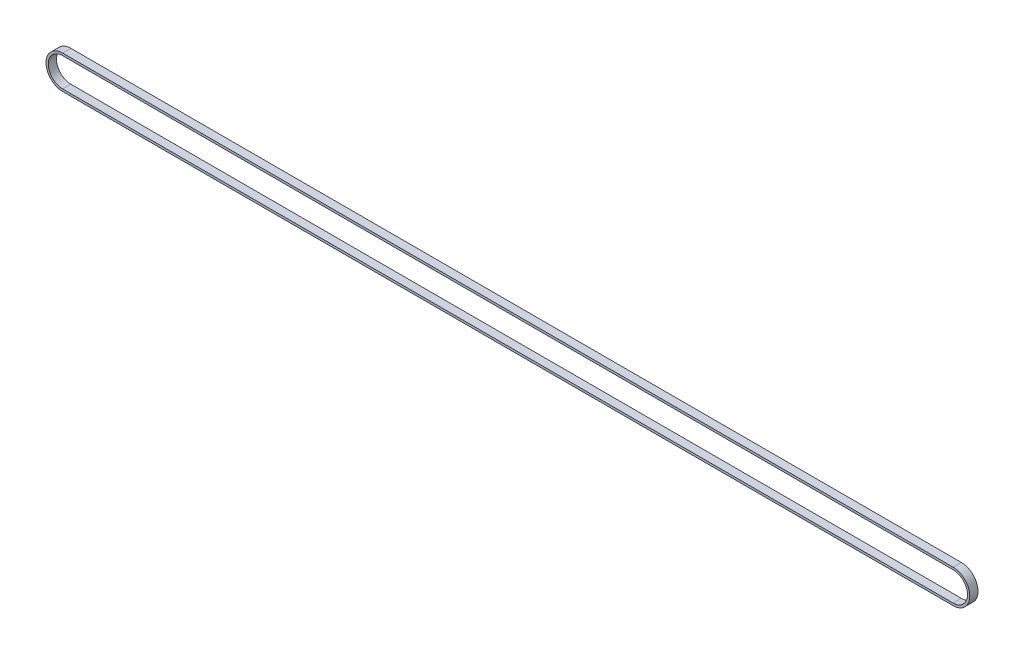
from build123d import *

# Parameters (mm, degrees)
EXTRUDE_THIN1_DEPTH = 2.5


with BuildPart() as part:
    # Sketch1 → Extrude-Thin1 (new body, symmetric)
    with BuildSketch(Plane.XY):
        with BuildLine():
            Line((541, -10.13), (0, -10.13))
            ThreePointArc((0, -10.13), (-10.13, 0), (0, 10.13))
            Line((0, 10.13), (541, 10.13))
            ThreePointArc((541, 10.13), (551.13, 0), (541, -10.13))
        make_face()
        with BuildLine():
            Line((541, -8.75), (0, -8.75))
            ThreePointArc((0, -8.75), (-8.75, 0), (0, 8.75))
            Line((0, 8.75), (541, 8.75))
            ThreePointArc((541, 8.75), (549.75, 0), (541, -8.75))
        make_face(mode=Mode.SUBTRACT)
    extrude(amount=EXTRUDE_THIN1_DEPTH, both=True)


solid = part.part
